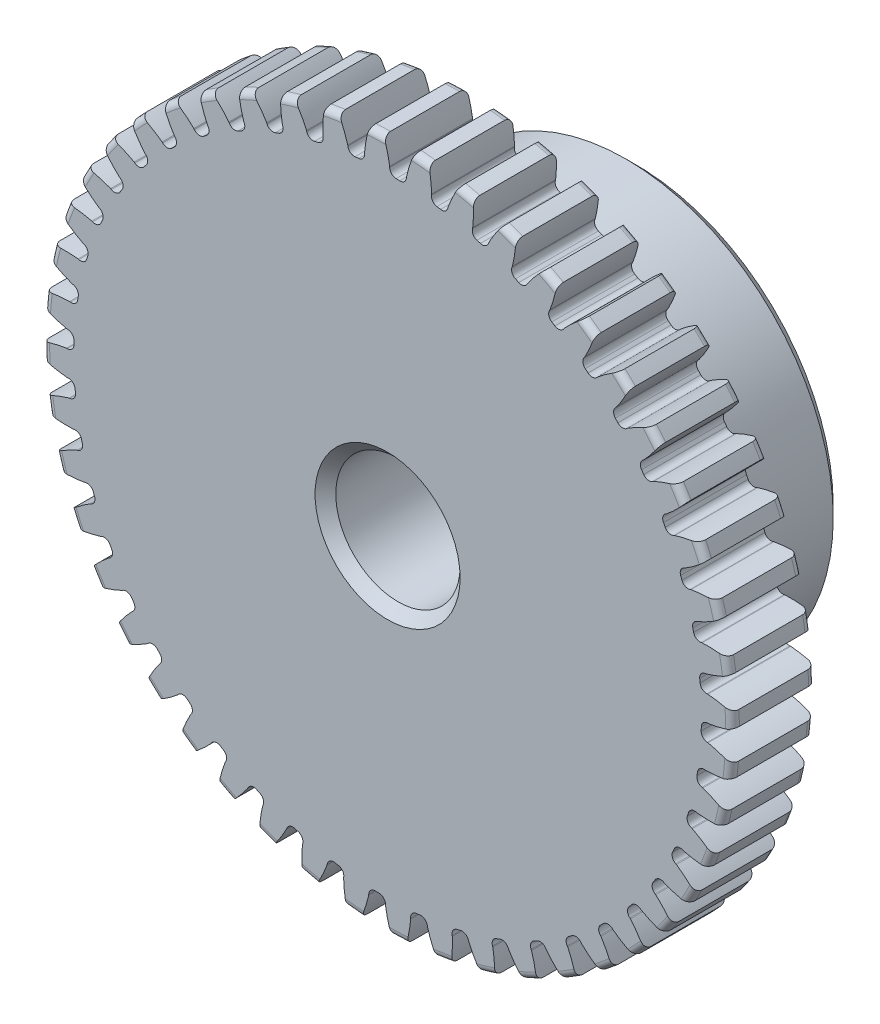
from build123d import *

# Parameters (mm, degrees)
SKETCH1_R                = 13.208
BOSS_EXTRUDE1_DEPTH      = 3.175
SKETCH2_W                = 6.35
SKETCH2_H                = 7.9375
FILLET2_R                = 0.26416
CUT_EXTRUDE1_DEPTH       = 10.525
FILLET1_R                = 0.2493645
CIRPATTERN1_COUNT        = 48
FILLET1_OF_CIRPATTERN1_R = 0.2493645
SKETCH5_R                = 2.38125
CUT_EXTRUDE2_DEPTH       = 10.525
CHAMFER1_SIZE            = 0.396875


with BuildPart() as part:
    # Sketch1 → Boss-Extrude1 (new body)
    with BuildSketch(Plane.XY):
        Circle(SKETCH1_R)
    extrude(amount=-BOSS_EXTRUDE1_DEPTH)

    # Sketch2 → Revolve1 (revolve)
    with BuildSketch(Plane(origin=(0, 0, 0), x_dir=(0, 0, -1), z_dir=(1, 0, 0))):
        with Locations((6.35, 3.96875)):
            Rectangle(SKETCH2_W, SKETCH2_H)
    revolve(axis=Axis((0, 0, -3.175), (0, 0, -1)))

    # Fillet2
    fillet2_edges = [part.edges().sort_by_distance(p)[0] for p in [
        (-13.208, 0, 0),
        (-13.208, 0, -3.175),
        (0, -7.9375, -3.175),
    ]]
    fillet(fillet2_edges, radius=FILLET2_R)

    # Sketch4 → Cut-Extrude1 (cut, through all)
    with BuildSketch(Plane.XY):
        with BuildLine():
            Line((0.079822856, 12.295215923), (0.079822856, 12.017109894))
            ThreePointArc((0.079822856, 12.017109894), (0.393198407, 12.010940717), (0.706306479, 11.996600896))
            Line((0.706306479, 11.996600896), (0.724495526, 12.274111476))
            add(Edge.make_bspline(
                [(2.238859643, 14.813576381), (1.043583933, 13.72829748), (0.724495526, 12.274111476)],
                knots=[0, 0, 0, 1, 1, 1], degree=2))
            ThreePointArc((2.238859643, 14.813576381), (0.490192126, 14.973785406), (-1.265209537, 14.928287997))
            add(Edge.make_bspline(
                [(-1.265209537, 14.928287997), (-0.143473818, 13.767157818), (0.079822856, 12.295215923)],
                knots=[0, 0, 0, 1, 1, 1], degree=2))
        make_face()
    cut_extrude1 = extrude(amount=-CUT_EXTRUDE1_DEPTH, mode=Mode.SUBTRACT)

    # Fillet1
    fillet1_edges = [part.edges().sort_by_distance(p)[0] for p in [
        (0.706306479, 11.996600896, -1.5875),
        (0.079822856, 12.017109894, -1.5875),
    ]]
    fillet(fillet1_edges, radius=FILLET1_R)

    # CirPattern1: Cut-Extrude1 ×48 about axis
    cirpattern1_axis = Axis((0, 0, -3.175), (0, 0, 1))
    for i in range(1, CIRPATTERN1_COUNT):
        add(cut_extrude1.rotate(cirpattern1_axis, i * 360 / CIRPATTERN1_COUNT), mode=Mode.SUBTRACT)

    # Fillet1 of CirPattern1
    fillet1_of_cirpattern1_edges = [part.edges().sort_by_distance(p)[0] for p in [
        (-0.865606706, 11.986159807, -1.5875),
        (-1.489407636, 11.924720826, -1.5875),
        (-2.422709119, 11.770632201, -1.5875),
        (-3.03315395, 11.628296479, -1.5875),
        (-3.938358308, 11.353705815, -1.5875),
        (-4.525002159, 11.132908755, -1.5875),
        (-5.386621094, 10.742514374, -1.5875),
        (-5.939426326, 10.447033876, -1.5875),
        (-6.7427173, 9.947515534, -1.5875),
        (-7.252225263, 9.582407351, -1.5875),
        (-7.983443744, 8.982311945, -1.5875),
        (-8.440936614, 8.553823179, -1.5875),
        (-9.087571251, 7.863418509, -1.5875),
        (-9.485221199, 7.378880721, -1.5875),
        (-10.036207895, 6.609979801, -1.5875),
        (-10.36721102, 6.077683568, -1.5875),
        (-10.81312224, 5.243442507, -1.5875),
        (-11.071814987, 4.672495564, -1.5875),
        (-11.405021064, 3.787188457, -1.5875),
        (-11.586977129, 3.187359865, -1.5875),
        (-11.801776817, 2.266134563, -1.5875),
        (-11.90388288, 1.647687556, -1.5875),
        (-11.996600896, 0.706306479, -1.5875),
        (-12.017109894, 0.079822856, -1.5875),
        (-11.986159807, -0.865606706, -1.5875),
        (-11.924720826, -1.489407636, -1.5875),
        (-11.770632201, -2.422709119, -1.5875),
        (-11.628296479, -3.03315395, -1.5875),
        (-11.353705815, -3.938358308, -1.5875),
        (-11.132908755, -4.525002159, -1.5875),
        (-10.742514374, -5.386621094, -1.5875),
        (-10.447033876, -5.939426326, -1.5875),
        (-9.947515534, -6.7427173, -1.5875),
        (-9.582407351, -7.252225263, -1.5875),
        (-8.982311945, -7.983443744, -1.5875),
        (-8.553823179, -8.440936614, -1.5875),
        (-7.863418509, -9.087571251, -1.5875),
        (-7.378880721, -9.485221199, -1.5875),
        (-6.609979801, -10.036207895, -1.5875),
        (-6.077683568, -10.36721102, -1.5875),
        (-5.243442507, -10.81312224, -1.5875),
        (-4.672495564, -11.071814987, -1.5875),
        (-3.787188457, -11.405021064, -1.5875),
        (-3.187359865, -11.586977129, -1.5875),
        (-2.266134563, -11.801776817, -1.5875),
        (-1.647687556, -11.90388288, -1.5875),
        (-0.706306479, -11.996600896, -1.5875),
        (-0.079822856, -12.017109894, -1.5875),
        (0.865606706, -11.986159807, -1.5875),
        (1.489407636, -11.924720826, -1.5875),
        (2.422709119, -11.770632201, -1.5875),
        (3.03315395, -11.628296479, -1.5875),
        (3.938358308, -11.353705815, -1.5875),
        (4.525002159, -11.132908755, -1.5875),
        (5.386621094, -10.742514374, -1.5875),
        (5.939426326, -10.447033876, -1.5875),
        (6.7427173, -9.947515534, -1.5875),
        (7.252225263, -9.582407351, -1.5875),
        (7.983443744, -8.982311945, -1.5875),
        (8.440936614, -8.553823179, -1.5875),
        (9.087571251, -7.863418509, -1.5875),
        (9.485221199, -7.378880721, -1.5875),
        (10.036207895, -6.609979801, -1.5875),
        (10.36721102, -6.077683568, -1.5875),
        (10.81312224, -5.243442507, -1.5875),
        (11.071814987, -4.672495564, -1.5875),
        (11.405021064, -3.787188457, -1.5875),
        (11.586977129, -3.187359865, -1.5875),
        (11.801776817, -2.266134563, -1.5875),
        (11.90388288, -1.647687556, -1.5875),
        (11.996600896, -0.706306479, -1.5875),
        (12.017109894, -0.079822856, -1.5875),
        (11.986159807, 0.865606706, -1.5875),
        (11.924720826, 1.489407636, -1.5875),
        (11.770632201, 2.422709119, -1.5875),
        (11.628296479, 3.03315395, -1.5875),
        (11.353705815, 3.938358308, -1.5875),
        (11.132908755, 4.525002159, -1.5875),
        (10.742514374, 5.386621094, -1.5875),
        (10.447033876, 5.939426326, -1.5875),
        (9.947515534, 6.7427173, -1.5875),
        (9.582407351, 7.252225263, -1.5875),
        (8.982311945, 7.983443744, -1.5875),
        (8.553823179, 8.440936614, -1.5875),
        (7.863418509, 9.087571251, -1.5875),
        (7.378880721, 9.485221199, -1.5875),
        (6.609979801, 10.036207895, -1.5875),
        (6.077683568, 10.36721102, -1.5875),
        (5.243442507, 10.81312224, -1.5875),
        (4.672495564, 11.071814987, -1.5875),
        (3.787188457, 11.405021064, -1.5875),
        (3.187359865, 11.586977129, -1.5875),
        (2.266134563, 11.801776817, -1.5875),
        (1.647687556, 11.90388288, -1.5875),
    ]]
    fillet(fillet1_of_cirpattern1_edges, radius=FILLET1_OF_CIRPATTERN1_R)

    # Sketch5 → Cut-Extrude2 (cut, through all)
    with BuildSketch(Plane.XY):
        Circle(SKETCH5_R)
    extrude(amount=-CUT_EXTRUDE2_DEPTH, mode=Mode.SUBTRACT)

    # Chamfer1
    chamfer1_edges = [part.edges().sort_by_distance(p)[0] for p in [
        (-2.38125, 0, -9.525),
        (-2.38125, 0, 0),
        (0, -7.9375, -9.525),
    ]]
    chamfer(chamfer1_edges, length=CHAMFER1_SIZE)


solid = part.part
